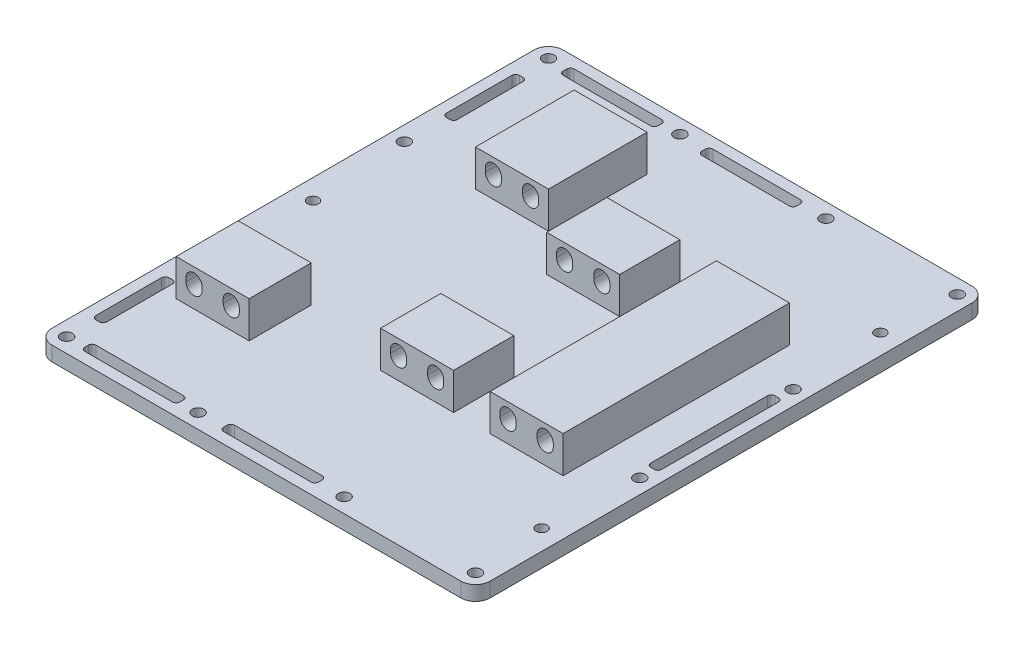
from build123d import *

# Parameters (mm, degrees)
SKETCH1_W               = 120
SKETCH1_H               = 140
BOSS_EXTRUDE1_DEPTH     = 4
SKETCH2_R               = 1.6
CUT_EXTRUDE1_DEPTH      = 4
FILLET1_R               = 4
SKETCH5_W               = 20
SKETCH5_H               = 62
SKETCH5_H_2             = 27
BOSS_EXTRUDE2_DEPTH     = 10
SKETCH6_W               = 20
SKETCH6_H               = 10
SKETCH6_H_2             = 29
CUT_EXTRUDE3_DEPTH      = 10
CUT_EXTRUDE4_DEPTH      = 40
CUT_EXTRUDE4_DEPTH_BACK = 102
CUT_EXTRUDE5_DEPTH      = 20
CUT_EXTRUDE6_DEPTH      = 30
CUT_EXTRUDE7_DEPTH      = 5
SKETCH11_R              = 1.5
CUT_EXTRUDE8_DEPTH      = 5


with BuildPart() as part:
    # Sketch1 → Boss-Extrude1 (new body)
    with BuildSketch(Plane(origin=(0, 0, 0), x_dir=(1, 0, 0), z_dir=(0, 1, 0))):
        Rectangle(SKETCH1_W, SKETCH1_H)
    extrude(amount=BOSS_EXTRUDE1_DEPTH)

    # Sketch2 → Cut-Extrude1 (cut)
    with BuildSketch(Plane(origin=(0, 4, 0), x_dir=(1, 0, 0), z_dir=(0, 1, 0))):
        with Locations((-56, 66)):
            Circle(SKETCH2_R)
        with Locations((56, 66)):
            Circle(SKETCH2_R)
        with Locations((-56, -66)):
            Circle(SKETCH2_R)
        with Locations((56, -66)):
            Circle(SKETCH2_R)
        with Locations((-20, -66)):
            Circle(SKETCH2_R)
        with Locations((20, -66)):
            Circle(SKETCH2_R)
        with Locations((-20, 66)):
            Circle(SKETCH2_R)
        with Locations((20, 66)):
            Circle(SKETCH2_R)
        with Locations((-56, -26.5)):
            Circle(SKETCH2_R)
        with Locations((-56, 26.5)):
            Circle(SKETCH2_R)
        with Locations((56, -21)):
            Circle(SKETCH2_R)
        with Locations((56, 21)):
            Circle(SKETCH2_R)
    extrude(amount=-CUT_EXTRUDE1_DEPTH, mode=Mode.SUBTRACT)

    # Fillet1
    fillet1_edges = [part.edges().sort_by_distance(p)[0] for p in [
        (60, 2, 70),
        (-60, 2, 70),
        (-60, 2, -70),
        (60, 2, -70),
    ]]
    fillet(fillet1_edges, radius=FILLET1_R)

    # Sketch5 → Boss-Extrude2 (add)
    with BuildSketch(Plane(origin=(0, 4, 0), x_dir=(1, 0, 0), z_dir=(0, 1, 0))):
        with Locations((35, 0)):
            Rectangle(SKETCH5_W, SKETCH5_H)
        with Locations((-25, 38.5)):
            Rectangle(SKETCH5_W, SKETCH5_H_2)
        with Locations((5, 0)):
            Rectangle(SKETCH5_W, SKETCH5_H)
        with Locations((-40, -38.5)):
            Rectangle(SKETCH5_W, SKETCH5_H_2)
    extrude(amount=BOSS_EXTRUDE2_DEPTH)

    # Sketch6 → Cut-Extrude3 (cut)
    with BuildSketch(Plane(origin=(0, 14, 0), x_dir=(1, 0, 0), z_dir=(0, 1, 0))):
        with Locations((-40, -47)):
            Rectangle(SKETCH6_W, SKETCH6_H)
        with Locations((5, 0)):
            Rectangle(SKETCH6_W, SKETCH6_H_2)
    extrude(amount=-CUT_EXTRUDE3_DEPTH, mode=Mode.SUBTRACT)

    # Sketch7 → Cut-Extrude4 (cut, two sides)
    with BuildSketch(Plane.XY.offset(31)) as cut_extrude4_sk:
        with BuildLine():
            Line((-2.3, 9.4), (-2.3, 10.4))
            ThreePointArc((-2.3, 10.4), (-0.1, 12.6), (2.1, 10.4))
            Line((2.1, 10.4), (2.1, 9.4))
            ThreePointArc((2.1, 9.4), (-0.1, 7.2), (-2.3, 9.4))
        make_face()
        with BuildLine():
            Line((7.9, 9.4), (7.9, 10.4))
            ThreePointArc((7.9, 10.4), (10.1, 12.6), (12.3, 10.4))
            Line((12.3, 10.4), (12.3, 9.4))
            ThreePointArc((12.3, 9.4), (10.1, 7.2), (7.9, 9.4))
        make_face()
        with BuildLine():
            Line((27.7, 9.4), (27.7, 10.4))
            ThreePointArc((27.7, 10.4), (29.9, 12.6), (32.1, 10.4))
            Line((32.1, 10.4), (32.1, 9.4))
            ThreePointArc((32.1, 9.4), (29.9, 7.2), (27.7, 9.4))
        make_face()
        with BuildLine():
            Line((37.9, 9.4), (37.9, 10.4))
            ThreePointArc((37.9, 10.4), (40.1, 12.6), (42.3, 10.4))
            Line((42.3, 10.4), (42.3, 9.4))
            ThreePointArc((42.3, 9.4), (40.1, 7.2), (37.9, 9.4))
        make_face()
    extrude(amount=CUT_EXTRUDE4_DEPTH, mode=Mode.SUBTRACT)
    extrude(cut_extrude4_sk.sketch, amount=-CUT_EXTRUDE4_DEPTH_BACK, mode=Mode.SUBTRACT)

    # Sketch8 → Cut-Extrude5 (cut)
    with BuildSketch(Plane.XY.offset(42)):
        with BuildLine():
            Line((-47.3, 9.4), (-47.3, 10.4))
            ThreePointArc((-47.3, 10.4), (-45.1, 12.6), (-42.9, 10.4))
            Line((-42.9, 10.4), (-42.9, 9.4))
            ThreePointArc((-42.9, 9.4), (-45.1, 7.2), (-47.3, 9.4))
        make_face()
        with BuildLine():
            Line((-37.1, 9.4), (-37.1, 10.4))
            ThreePointArc((-37.1, 10.4), (-34.9, 12.6), (-32.7, 10.4))
            Line((-32.7, 10.4), (-32.7, 9.4))
            ThreePointArc((-32.7, 9.4), (-34.9, 7.2), (-37.1, 9.4))
        make_face()
    extrude(amount=-CUT_EXTRUDE5_DEPTH, mode=Mode.SUBTRACT)

    # Sketch9 → Cut-Extrude6 (cut)
    with BuildSketch(Plane(origin=(0, 0, -52), x_dir=(-1, 0, 0), z_dir=(0, 0, -1))):
        with BuildLine():
            Line((17.7, 9.4), (17.7, 10.4))
            ThreePointArc((17.7, 10.4), (19.9, 12.6), (22.1, 10.4))
            Line((22.1, 10.4), (22.1, 9.4))
            ThreePointArc((22.1, 9.4), (19.9, 7.2), (17.7, 9.4))
        make_face()
        with BuildLine():
            Line((27.9, 9.4), (27.9, 10.4))
            ThreePointArc((27.9, 10.4), (30.1, 12.6), (32.3, 10.4))
            Line((32.3, 10.4), (32.3, 9.4))
            ThreePointArc((32.3, 9.4), (30.1, 7.2), (27.9, 9.4))
        make_face()
    extrude(amount=-CUT_EXTRUDE6_DEPTH, mode=Mode.SUBTRACT)

    # Sketch10 → Cut-Extrude7 (cut, through all)
    with BuildSketch(Plane(origin=(0, 4, 0), x_dir=(1, 0, 0), z_dir=(0, 1, 0))):
        with BuildLine():
            Line((-56, 58), (-55, 58))
            ThreePointArc((-55, 58), (-54.292893219, 57.707106781), (-54, 57))
            Line((-54, 57), (-54, 39))
            ThreePointArc((-54, 39), (-54.292893219, 38.292893219), (-55, 38))
            Line((-55, 38), (-56, 38))
            ThreePointArc((-56, 38), (-56.707106781, 38.292893219), (-57, 39))
            Line((-57, 39), (-57, 57))
            ThreePointArc((-57, 57), (-56.707106781, 57.707106781), (-56, 58))
        make_face()
        with BuildLine():
            Line((-50, 67), (-26, 67))
            ThreePointArc((-26, 67), (-25.292893219, 66.707106781), (-25, 66))
            Line((-25, 66), (-25, 65))
            ThreePointArc((-25, 65), (-25.292893219, 64.292893219), (-26, 64))
            Line((-26, 64), (-50, 64))
            ThreePointArc((-50, 64), (-50.707106781, 64.292893219), (-51, 65))
            Line((-51, 65), (-51, 66))
            ThreePointArc((-51, 66), (-50.707106781, 66.707106781), (-50, 67))
        make_face()
        with BuildLine():
            Line((-12, 67), (12, 67))
            ThreePointArc((12, 67), (12.707106781, 66.707106781), (13, 66))
            Line((13, 66), (13, 65))
            ThreePointArc((13, 65), (12.707106781, 64.292893219), (12, 64))
            Line((12, 64), (-12, 64))
            ThreePointArc((-12, 64), (-12.707106781, 64.292893219), (-13, 65))
            Line((-13, 65), (-13, 66))
            ThreePointArc((-13, 66), (-12.707106781, 66.707106781), (-12, 67))
        make_face()
        with BuildLine():
            Line((55, 17), (56, 17))
            ThreePointArc((56, 17), (56.707106781, 16.707106781), (57, 16))
            Line((57, 16), (57, -16))
            ThreePointArc((57, -16), (56.707106781, -16.707106781), (56, -17))
            Line((56, -17), (55, -17))
            ThreePointArc((55, -17), (54.292893219, -16.707106781), (54, -16))
            Line((54, -16), (54, 16))
            ThreePointArc((54, 16), (54.292893219, 16.707106781), (55, 17))
        make_face()
    cut_extrude7 = extrude(amount=-CUT_EXTRUDE7_DEPTH, mode=Mode.SUBTRACT)

    # Mirror1: Cut-Extrude7 across plane
    add(cut_extrude7.mirror(Plane.XY), mode=Mode.SUBTRACT)

    # Sketch11 → Cut-Extrude8 (cut, through all)
    with BuildSketch(Plane(origin=(0, 4, 0), x_dir=(1, 0, 0), z_dir=(0, 1, 0))):
        with Locations((-54.5, 0)):
            Circle(SKETCH11_R)
        with Locations((54.5, -46.4)):
            Circle(SKETCH11_R)
        with Locations((54.5, 46.4)):
            Circle(SKETCH11_R)
    extrude(amount=-CUT_EXTRUDE8_DEPTH, mode=Mode.SUBTRACT)


solid = part.part
